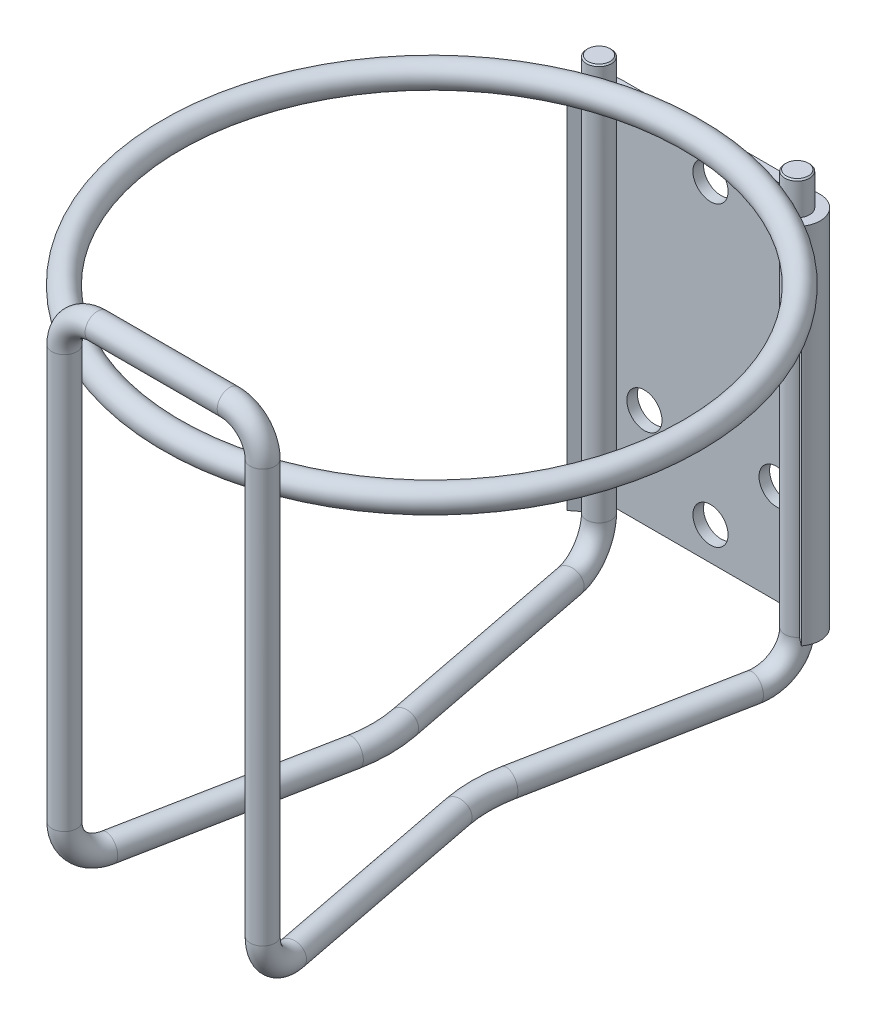
from build123d import *

# Parameters (mm, degrees)
SKETCH1_W           = 38.1
SKETCH1_H           = 69.85
SKETCH1_R           = 3.3782
BOSS_EXTRUDE1_DEPTH = 2.032
SKETCH5_R           = 2.38125
SKETCH10_R          = 2.38125
SKETCH11_R          = 2.38125
SKETCH16_R          = 2.38125
CUT_EXTRUDE2_DEPTH  = 3.175
SKETCH14_R          = 2.38125
SKETCH7_R           = 2.38125
BOSS_EXTRUDE8_DEPTH = 69.85
CHAMFER1_SIZE       = 0.254


with BuildPart() as part:
    # Sketch1 → Boss-Extrude1 (new body)
    with BuildSketch(Plane.XY):
        Rectangle(SKETCH1_W, SKETCH1_H)
        with Locations((0, 28.575)):
            Circle(SKETCH1_R, mode=Mode.SUBTRACT)
        with Locations((0, -28.575)):
            Circle(SKETCH1_R, mode=Mode.SUBTRACT)
        with Locations((-12.7, -15.875)):
            Circle(SKETCH1_R, mode=Mode.SUBTRACT)
        with Locations((12.7, -15.875)):
            Circle(SKETCH1_R, mode=Mode.SUBTRACT)
    extrude(amount=-BOSS_EXTRUDE1_DEPTH)


with BuildPart() as body_2:
    # Sweep7: sweep along a path in Sketch4
    with BuildLine(Plane(origin=(19.05, 0, 0), x_dir=(0, 0, -1), z_dir=(1, 0, 0))) as sweep7_path:
        Line((-2.38125, 41.275), (-2.38125, -34.925))
    # Sketch5 → Sweep7 (sweep)
    with BuildSketch(Plane.XZ.offset(-41.275)):
        with Locations((19.05, 2.38125)):
            Circle(SKETCH5_R)
    sweep(path=sweep7_path.line)

    # Sweep4: sweep along a path in Sketch9
    with BuildLine(Plane(origin=(18.800930134, 0, 3.660510229), x_dir=(-0.1911098072603005, 0, 0.981568663705668), z_dir=(-0.9815686637056681, 0, -0.19110980726030052))) as sweep4_path:
        ThreePointArc((5.840468552, -42.06875), (0.789074484, -39.976394068), (-1.303281448, -34.925))
    # Sketch10 → Sweep4 (sweep)
    with BuildSketch(Plane.XZ.offset(34.925)):
        with Locations((19.05, 2.38125)):
            Circle(SKETCH10_R)
    sweep(path=sweep4_path.line)

    # Sweep5: sweep along a path in Sketch8
    with BuildLine(Plane(origin=(0, -42.06875, 0), x_dir=(1, 0, 0), z_dir=(0, 1, 0))) as sweep5_path:
        Line((17.684759314, -9.393331141), (9.993155942, -48.898560896))
        ThreePointArc((9.993155942, -48.898560896), (9.642309883, -51.314393902), (9.525, -53.75275))
    # Sketch11 → Sweep5 (sweep)
    with BuildSketch(Plane(origin=(-1.116170819, 0, 5.732820912), x_dir=(0.981568663705668, 0, 0.19110980726030052), z_dir=(-0.19110980726030055, 0, 0.9815686637056681))):
        with Locations((19.153963272, -42.06875)):
            Circle(SKETCH11_R)
    sweep(path=sweep5_path.line)

    # Mirror8: body 2 across plane


with BuildPart() as body_2_1:
    add(body_2.part)
    add(body_2.part.mirror(Plane(origin=(9.525, -42.06875, 53.75275), x_dir=(1, 0, 0), z_dir=(0, 0, 1))))


with BuildPart() as body_3:
    # Mirror6: mirrored copy
    add(body_2_1.part.mirror(Plane(origin=(0, 0, 0), x_dir=(0, 0, 1), z_dir=(1, 0, 0))))


with BuildPart() as cut_extrude2_tool:
    # Sketch16 → Cut-Extrude2 (new body)
    with BuildSketch(Plane(origin=(0, 41.275, 0), x_dir=(1, 0, 0), z_dir=(0, 1, 0))):
        with Locations(Location((-19.05, -105.12425, 0), (0, 0, 258.982441638))):
            Circle(SKETCH16_R)
        with Locations(Location((19.05, -105.12425, 0), (0, 0, 281.017558362))):
            Circle(SKETCH16_R)
    extrude(amount=-CUT_EXTRUDE2_DEPTH)


with BuildPart() as body_2_2:
    add(body_2_1.part)

    # Cut-Extrude2: cut by cut_extrude2_tool
    add(cut_extrude2_tool.part, mode=Mode.SUBTRACT)



with BuildPart() as body_3_1:
    add(body_3.part)

    # Cut-Extrude2: cut by cut_extrude2_tool
    add(cut_extrude2_tool.part, mode=Mode.SUBTRACT)


with BuildPart() as body_2_3:
    add(body_2_2.part)

    add(body_3_1.part)  # Sweep9 merges body 3
    # Sweep9: sweep along a path in Sketch13
    with BuildLine(Plane.XY.offset(105.12425)) as sweep9_path:
        Line((-19.05, 38.1), (-19.05, 44.45))
        ThreePointArc((-19.05, 44.45), (-17.190128061, 48.940128061), (-12.7, 50.8))
        Line((-12.7, 50.8), (12.7, 50.8))
        ThreePointArc((12.7, 50.8), (17.190128061, 48.940128061), (19.05, 44.45))
        Line((19.05, 44.45), (19.05, 38.1))
    # Sketch14 → Sweep9 (sweep)
    with BuildSketch(Plane(origin=(0, 38.1, 0), x_dir=(1, 0, 0), z_dir=(0, 1, 0))):
        with Locations((19.05, -105.12425)):
            Circle(SKETCH14_R)
    sweep(path=sweep9_path.line)

    # Chamfer1
    chamfer1_edges = [body_2_3.edges().sort_by_distance(p)[0] for p in [
        (16.66875, 41.275, 2.38125),
        (-16.66875, 41.275, 2.38125),
    ]]
    chamfer(chamfer1_edges, length=CHAMFER1_SIZE)


with BuildPart() as body_3_2:
    # Sweep8: sweep along a path in Sketch6
    with BuildLine(Plane(origin=(0, 38.1, 0), x_dir=(1, 0, 0), z_dir=(0, 1, 0))) as sweep8_path:
        CenterArc((0, -53.563603023), 50.00625, 0, 360)
    # Sketch7 → Sweep8 (sweep)
    with BuildSketch(Plane(origin=(0, 0, 0), x_dir=(0, 0, -1), z_dir=(1, 0, 0))):
        with Locations((-3.557353023, 38.1)):
            Circle(SKETCH7_R)
    sweep(path=sweep8_path.line)


with BuildPart() as body_4:
    # Sketch18 → Boss-Extrude8 (new body)
    with BuildSketch(Plane(origin=(0, 34.925, 0), x_dir=(1, 0, 0), z_dir=(0, 1, 0))):
        with BuildLine():
            Line((-20.934130942, -3.837410072), (-22.54192268, -5.08))
            ThreePointArc((-22.54192268, -5.08), (-23.011504386, -0.436189959), (-19.05, 2.032))
            Line((-19.05, 2.032), (-19.05, 0))
            ThreePointArc((-19.05, 0), (-21.187502367, -1.331757172), (-20.934130942, -3.837410072))
        make_face()
    extrude(amount=-BOSS_EXTRUDE8_DEPTH)


with BuildPart() as body_5:
    # Mirror9: mirrored copy
    add(body_4.part.mirror(Plane(origin=(0, 0, 0), x_dir=(0, 0, 1), z_dir=(1, 0, 0))))


with BuildPart() as body_4_1:
    add(body_4.part)

    # Combine1: union part, body 5
    add(part.part)
    add(body_5.part)


solid = Compound([body_2_3.part, body_3_2.part, body_4_1.part])
